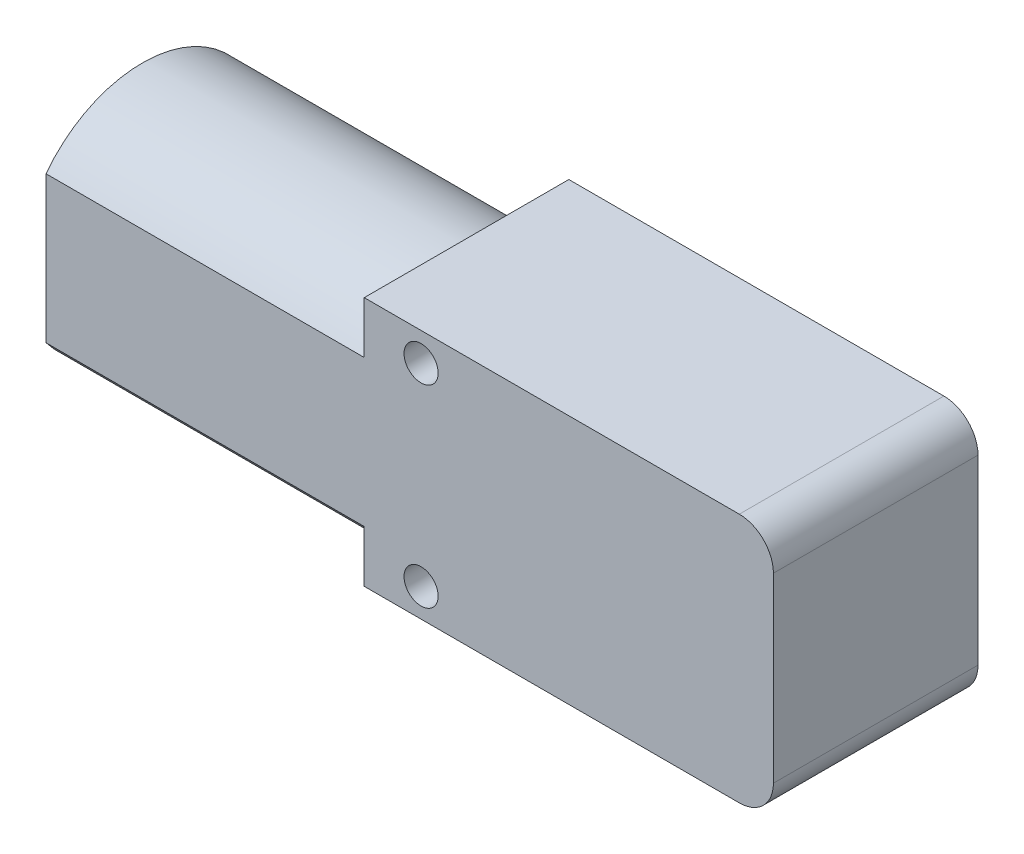
from build123d import *

# Parameters (mm, degrees)
SCHIZZO1_W                   = 36
SCHIZZO1_H                   = 22
ESTRUSIONE_ESTRUSIONE1_DEPTH = 18
RACCORDO1_R                  = 3
ESTRUSIONE_ESTRUSIONE2_DEPTH = 28
SCHIZZO3_R                   = 2.5
ESTRUSIONE_ESTRUSIONE3_DEPTH = 8
SCHIZZO3_4_R                 = 1.5
TAGLIO_ESTRUSIONE1_DEPTH     = 51.606323716


with BuildPart() as part:
    # Schizzo1 → Estrusione-Estrusione1 (new body)
    with BuildSketch(Plane.XY):
        Rectangle(SCHIZZO1_W, SCHIZZO1_H)
    extrude(amount=ESTRUSIONE_ESTRUSIONE1_DEPTH)

    # Raccordo1
    raccordo1_edges = [part.edges().sort_by_distance(p)[0] for p in [
        (18, -11, 9),
        (18, 11, 9),
    ]]
    fillet(raccordo1_edges, radius=RACCORDO1_R)

    # Schizzo2 → Estrusione-Estrusione2 (add)
    with BuildSketch(Plane.ZY.offset(18)):
        with BuildLine():
            Line((1.5, 7), (1.5, -7))
            ThreePointArc((1.5, -7), (9.883293707, -10.640228974), (18, -6.439043509))
            Line((18, -6.439043509), (18, 6.439043509))
            ThreePointArc((18, 6.439043509), (9.883293707, 10.640228974), (1.5, 7))
        make_face()
    extrude(amount=ESTRUSIONE_ESTRUSIONE2_DEPTH)

    # Schizzo3 → Estrusione-Estrusione3 (add)
    with BuildSketch(Plane(origin=(0, 0, 0), x_dir=(-1, 0, 0), z_dir=(0, 0, -1))):
        with Locations((-6, 0)):
            Circle(SCHIZZO3_R)
    extrude(amount=ESTRUSIONE_ESTRUSIONE3_DEPTH)

    # Schizzo3_4 → Taglio-Estrusione1 (cut, through all)
    with BuildSketch(Plane(origin=(0, 0, 0), x_dir=(-1, 0, 0), z_dir=(0, 0, -1))):
        with Locations((13, 8.5)):
            Circle(SCHIZZO3_4_R)
        with Locations((13, -8.5)):
            Circle(SCHIZZO3_4_R)
    extrude(amount=-TAGLIO_ESTRUSIONE1_DEPTH, mode=Mode.SUBTRACT)


solid = part.part
